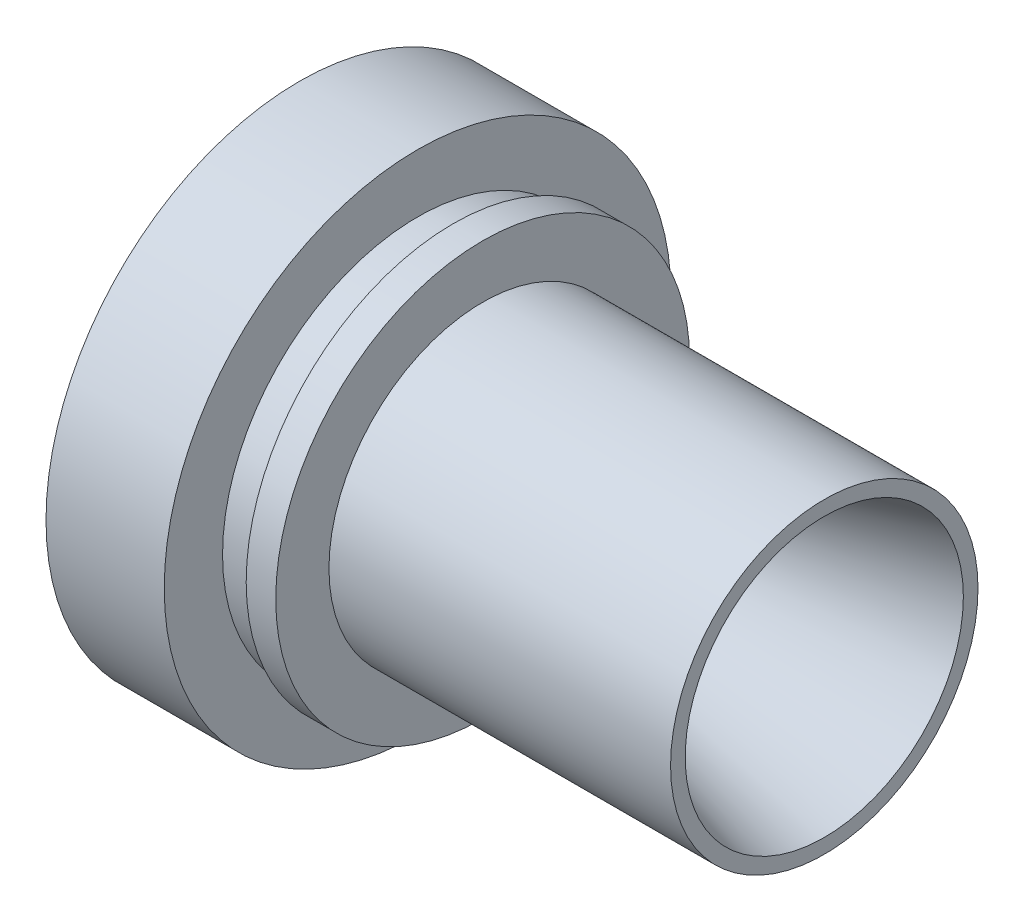
from build123d import *


with BuildPart() as part:
    # Sketch1 → Revolve1 (revolve)
    with BuildSketch(Plane.XY):
        with BuildLine():
            Line((-20, 42.86), (7.886601718, 14.973398282))
            ThreePointArc((7.886601718, 14.973398282), (14.610917759, 11.091112606), (22.375489112, 11.091112606))
            Line((22.375489112, 11.091112606), (68.779388603, 23.525))
            Line((68.779388603, 23.525), (68.779388603, 26))
            Line((68.779388603, 26), (11, 26))
            Line((11, 26), (11, 35))
            Line((11, 35), (6, 35))
            Line((6, 35), (6, 33))
            Line((6, 33), (0, 33))
            Line((0, 33), (0, 42.86))
            Line((0, 42.86), (-20, 42.86))
        make_face()
    revolve(axis=Axis((0, 0, 0), (-1, 0, 0)))


solid = part.part
